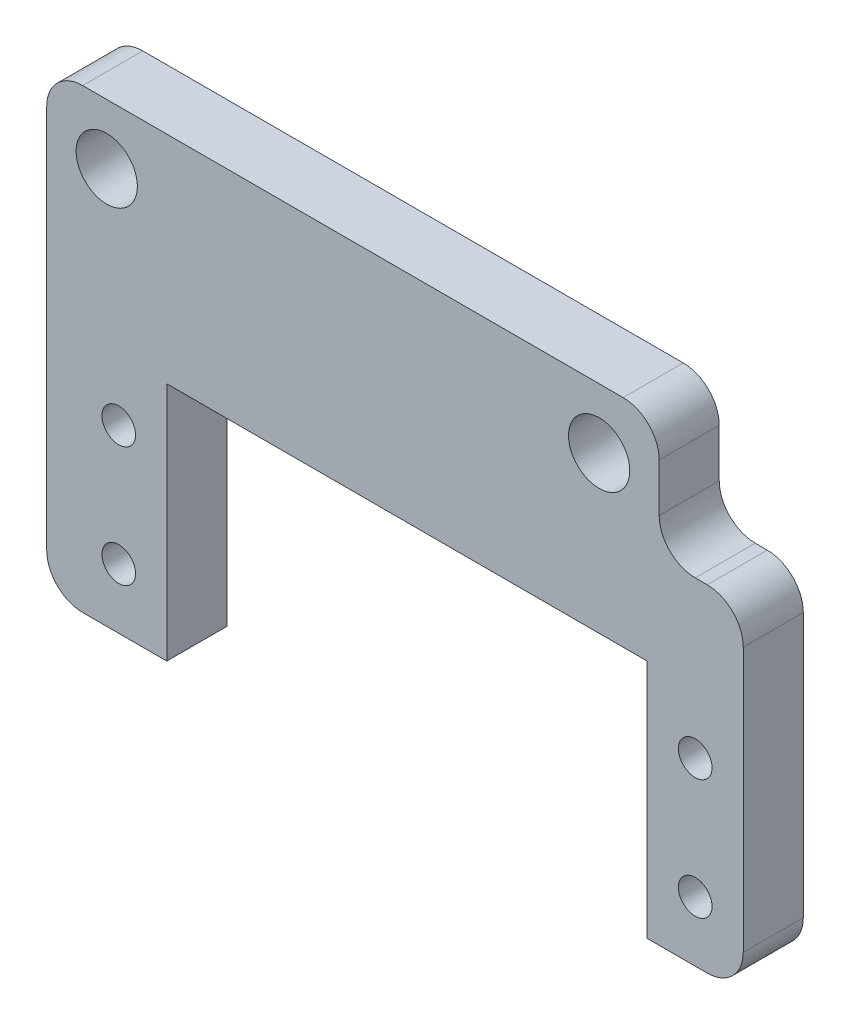
from build123d import *

# Parameters (mm, degrees)
SKETCH1_W           = 51
SKETCH1_H           = 10
SKETCH1_R           = 2.55
BOSS_EXTRUDE1_DEPTH = 5
SKETCH2_R           = 1.4
BOSS_EXTRUDE2_DEPTH = 5
FILLET1_R           = 3


with BuildPart() as part:
    # Sketch1 → Boss-Extrude1 (new body)
    with BuildSketch(Plane.XY):
        with Locations((25.5, 5)):
            Rectangle(SKETCH1_W, SKETCH1_H)
        with Locations((5, 5)):
            Circle(SKETCH1_R, mode=Mode.SUBTRACT)
        with Locations((46, 5)):
            Circle(SKETCH1_R, mode=Mode.SUBTRACT)
    extrude(amount=BOSS_EXTRUDE1_DEPTH)

    # Sketch2 → Boss-Extrude2 (add)
    with BuildSketch(Plane.XY.offset(5)):
        Polygon((10, -28), (10, -8), (50, -8), (50, -28), (58, -28), (58, 0), (51, 0), (0, 0), (0, -28), align=None)
        with Locations((6, -23)):
            Circle(SKETCH2_R, mode=Mode.SUBTRACT)
        with Locations((6, -13)):
            Circle(SKETCH2_R, mode=Mode.SUBTRACT)
        with Locations((54, -23)):
            Circle(SKETCH2_R, mode=Mode.SUBTRACT)
        with Locations((54, -13)):
            Circle(SKETCH2_R, mode=Mode.SUBTRACT)
    extrude(amount=-BOSS_EXTRUDE2_DEPTH)

    # Fillet1
    fillet1_edges = [part.edges().sort_by_distance(p)[0] for p in [
        (0, -28, 2.5),
        (58, 0, 2.5),
        (58, -28, 2.5),
        (0, 10, 2.5),
        (51, 10, 2.5),
        (51, 0, 2.5),
    ]]
    fillet(fillet1_edges, radius=FILLET1_R)


solid = part.part
